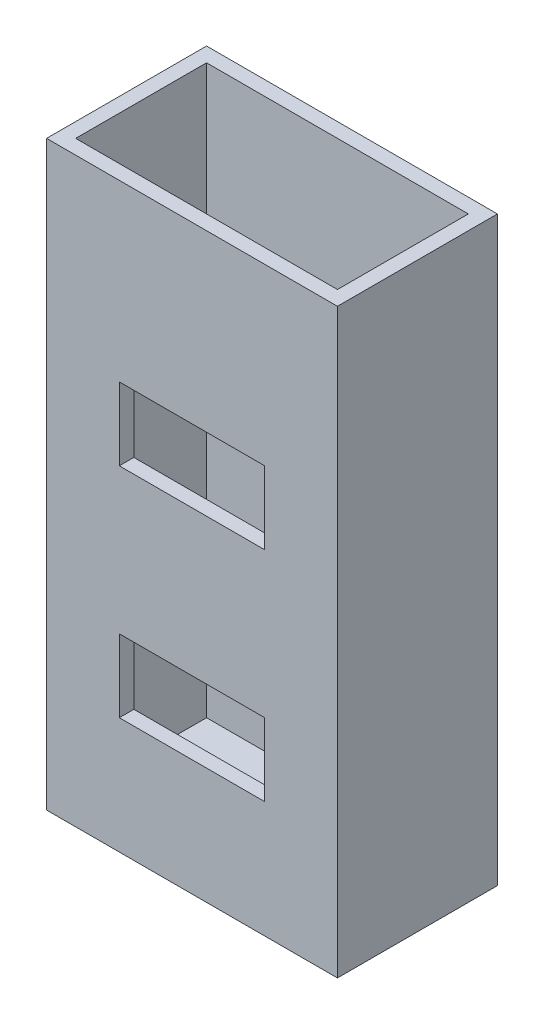
from build123d import *

# Parameters (mm, degrees)
SKETCH1_W               = 20
SKETCH1_H               = 40
BOSS_EXTRUDE1_DEPTH     = 11
SKETCH2_W               = 18
SKETCH2_H               = 9
CUT_EXTRUDE1_DEPTH      = 39
SKETCH3_W               = 10
SKETCH3_H               = 5
CUT_EXTRUDE2_DEPTH      = 6
CUT_EXTRUDE2_DEPTH_BACK = 4


with BuildPart() as part:
    # Sketch1 → Boss-Extrude1 (new body)
    with BuildSketch(Plane.XY):
        with Locations((-15.909713685, 10.402437659)):
            Rectangle(SKETCH1_W, SKETCH1_H)
    extrude(amount=BOSS_EXTRUDE1_DEPTH)

    # Sketch2 → Cut-Extrude1 (cut)
    with BuildSketch(Plane(origin=(0, 30.402437659, 0), x_dir=(1, 0, 0), z_dir=(0, 1, 0))):
        with Locations((-15.909713685, -5.5)):
            Rectangle(SKETCH2_W, SKETCH2_H)
    extrude(amount=-CUT_EXTRUDE1_DEPTH, mode=Mode.SUBTRACT)

    # Sketch3 → Cut-Extrude2 (cut, two sides)
    with BuildSketch(Plane.XY.offset(11)) as cut_extrude2_sk:
        with Locations((-15.909713685, 15.902437659)):
            Rectangle(SKETCH3_W, SKETCH3_H)
        with Locations((-15.909713685, 0.902437659)):
            Rectangle(SKETCH3_W, SKETCH3_H)
    extrude(amount=CUT_EXTRUDE2_DEPTH, mode=Mode.SUBTRACT)
    extrude(cut_extrude2_sk.sketch, amount=-CUT_EXTRUDE2_DEPTH_BACK, mode=Mode.SUBTRACT)


solid = part.part
